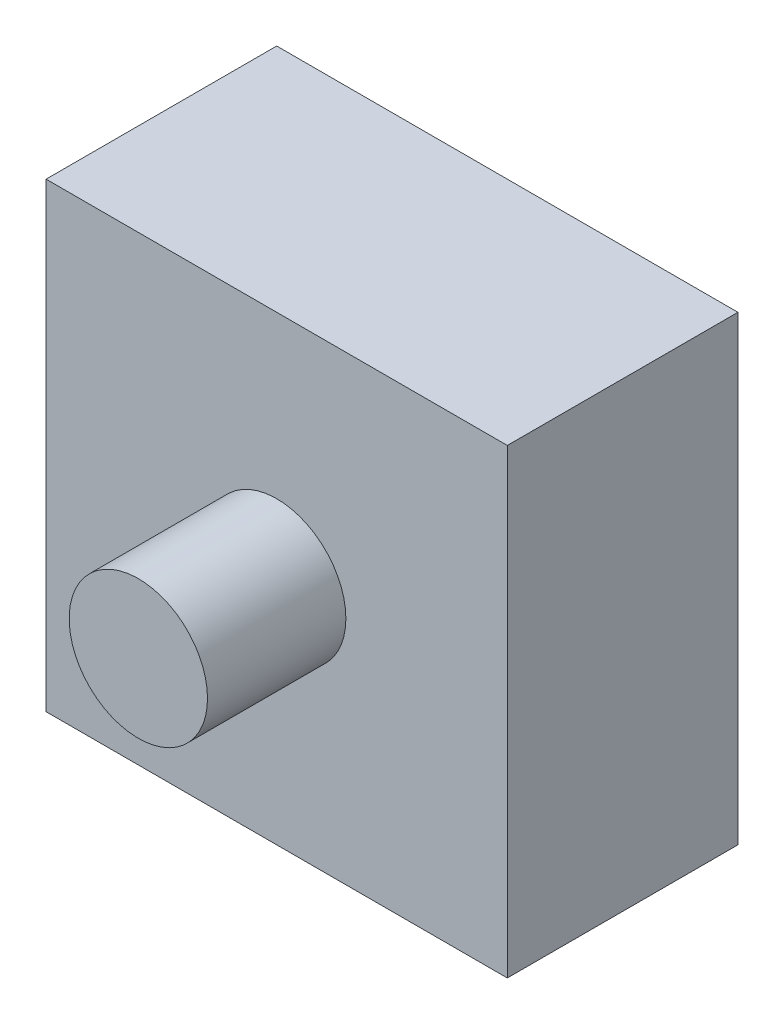
from build123d import *

# Parameters (mm, degrees)
SKETCH1_W           = 100
SKETCH1_H           = 100
BOSS_EXTRUDE1_DEPTH = 50
SKETCH2_R           = 15
BOSS_EXTRUDE2_DEPTH = 30


with BuildPart() as part:
    # Sketch1 → Boss-Extrude1 (new body)
    with BuildSketch(Plane.XY):
        Rectangle(SKETCH1_W, SKETCH1_H)
    extrude(amount=BOSS_EXTRUDE1_DEPTH)

    # Sketch2 → Boss-Extrude2 (add)
    with BuildSketch(Plane.XY.offset(50)):
        Circle(SKETCH2_R)
    extrude(amount=BOSS_EXTRUDE2_DEPTH)


solid = part.part
